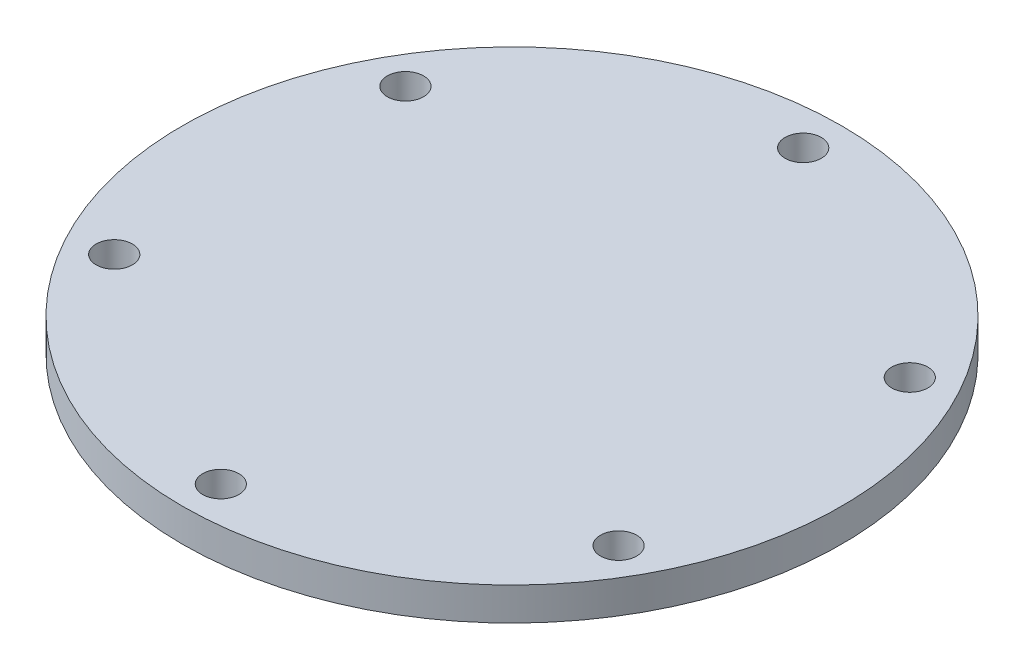
from build123d import *

# Parameters (mm, degrees)
CROQUIS1_R                   = 50
SALIENTE_EXTRUIR1_DEPTH      = 5
TALADRO_DE_MARGEN_PARA_M51_D = 5.5
MATRIZC1_COUNT               = 6


with BuildPart() as part:
    # Croquis1 → Saliente-Extruir1 (new body)
    with BuildSketch(Plane(origin=(0, 0, 0), x_dir=(1, 0, 0), z_dir=(0, 1, 0))):
        Circle(CROQUIS1_R)
    extrude(amount=SALIENTE_EXTRUIR1_DEPTH)

    # Taladro de margen para M51 (through all)
    with Locations(Plane(origin=(0, 0, 0), x_dir=(-1, 0, 0), z_dir=(0, -1, 0))):
        with Locations((0, 44.178034415)):
            taladro_de_margen_para_m51 = Hole(TALADRO_DE_MARGEN_PARA_M51_D / 2)

    # MatrizC1: Taladro de margen para M51 ×6 about axis
    matrizc1_axis = Axis((0, 0, 0), (0, 1, 0))
    for i in range(1, MATRIZC1_COUNT):
        add(taladro_de_margen_para_m51.rotate(matrizc1_axis, i * 360 / MATRIZC1_COUNT), mode=Mode.SUBTRACT)


solid = part.part
